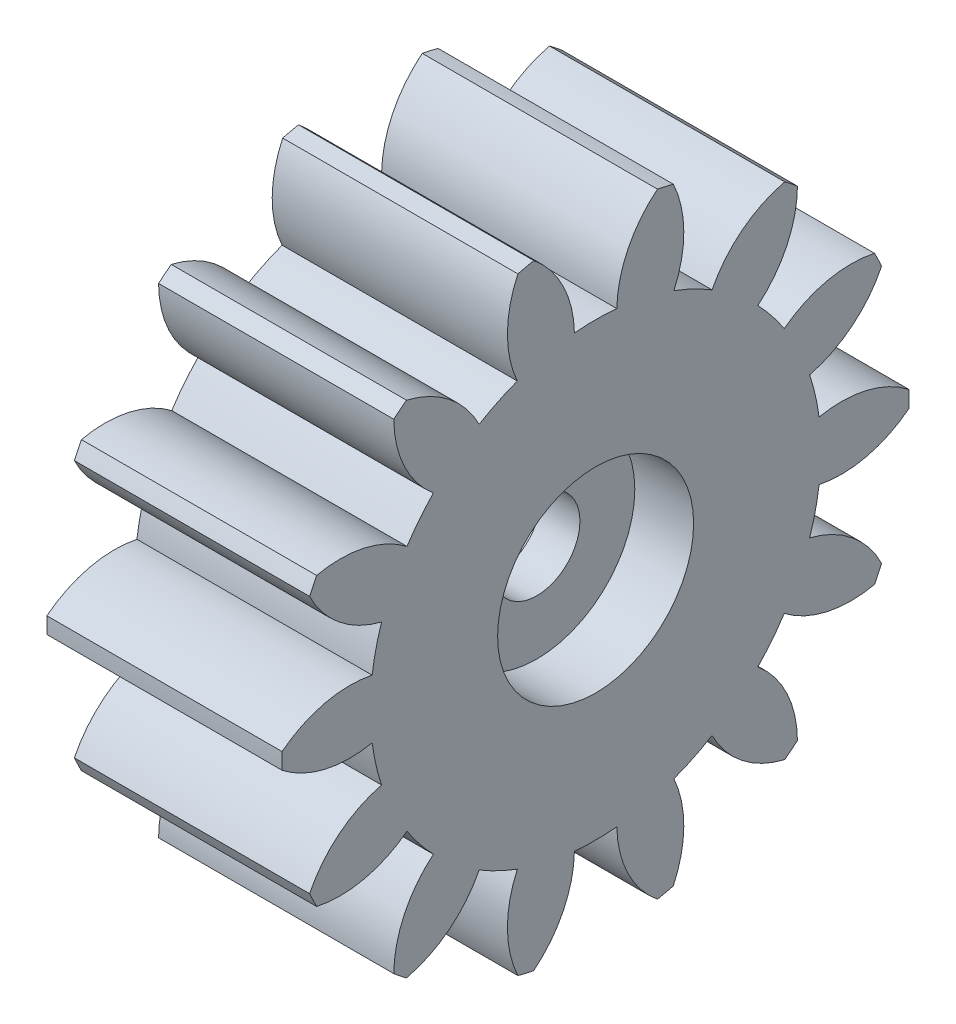
from build123d import *

# Parameters (mm, degrees)
BASPROSKE_W         = 6
BASPROSKE_H         = 8
TOOTHCUT_DEPTH      = 13.806248475
TEETHCUTS_COUNT     = 14
TEETHCUTS_ANGLE     = 334.285714286
BORSKE_R            = 2.5
BORE_DEPTH          = 50.0000508
SKETCH1_R           = 2.5
BOSS_EXTRUDE1_DEPTH = 2.5
SKETCH2_R           = 2.5
CUT_EXTRUDE1_DEPTH  = 1.5
SKETCH3_R           = 1.1
CUT_EXTRUDE2_DEPTH  = 13.073146116


with BuildPart() as part:
    # BasProSke → Base-Revolve (revolve)
    with BuildSketch(Plane(origin=(0, 0, 0), x_dir=(1, 0, 0), z_dir=(0, 1, 0)), mode=Mode.PRIVATE) as base_revolve_sk:
        with Locations((3, 4)):
            Rectangle(BASPROSKE_W, BASPROSKE_H)
    revolve(base_revolve_sk.sketch.rotate(Axis((-10, 0, 0), (1, 0, 0)), 180), axis=Axis((-10, 0, 0), (1, 0, 0)))

    # TooCutSke → ToothCut (cut, through all)
    with BuildSketch(Plane(origin=(0, 0, 0), x_dir=(0, 0, -1), z_dir=(1, 0, 0))):
        with BuildLine():
            ThreePointArc((0.540393256, 5.723545765), (0, 5.749), (-0.540393256, 5.723545765))
            ThreePointArc((-0.540393256, 5.723545765), (-0.832220085, 6.912663993), (-1.603550271, 7.863566092))
            ThreePointArc((-1.603550271, 7.863566092), (0, 8.0254), (1.603550271, 7.863566092))
            ThreePointArc((1.603550271, 7.863566092), (0.832220085, 6.912663993), (0.540393256, 5.723545765))
        make_face()
    toothcut = extrude(amount=TOOTHCUT_DEPTH, mode=Mode.SUBTRACT)

    # TeethCuts: ToothCut ×14 about axis
    teethcuts_axis = Axis((-10, 0, 0), (1, 0, 0))
    for i in range(1, TEETHCUTS_COUNT):
        add(toothcut.rotate(teethcuts_axis, i * TEETHCUTS_ANGLE / (TEETHCUTS_COUNT - 1)), mode=Mode.SUBTRACT)

    # BorSke → Bore (cut, symmetric)
    with BuildSketch(Plane(origin=(0, 0, 0), x_dir=(0, 0, -1), z_dir=(1, 0, 0))):
        with Locations(Location((0, 0, 0), (0, 0, 180))):
            Circle(BORSKE_R)
    extrude(amount=BORE_DEPTH, both=True, mode=Mode.SUBTRACT)

    # Sketch1 → Boss-Extrude1 (add)
    with BuildSketch(Plane(origin=(6, 0, 0), x_dir=(0, 0, -1), z_dir=(1, 0, 0))):
        Circle(SKETCH1_R)
    extrude(amount=-BOSS_EXTRUDE1_DEPTH)

    # Sketch2 → Cut-Extrude1 (cut)
    with BuildSketch(Plane(origin=(6, 0, 0), x_dir=(0, 0, -1), z_dir=(1, 0, 0))):
        Circle(SKETCH2_R)
    extrude(amount=-CUT_EXTRUDE1_DEPTH, mode=Mode.SUBTRACT)

    # Sketch3 → Cut-Extrude2 (cut, through all)
    with BuildSketch(Plane(origin=(4.5, 0, 0), x_dir=(0, 0, -1), z_dir=(1, 0, 0))):
        Circle(SKETCH3_R)
    extrude(amount=-CUT_EXTRUDE2_DEPTH, mode=Mode.SUBTRACT)


solid = part.part
